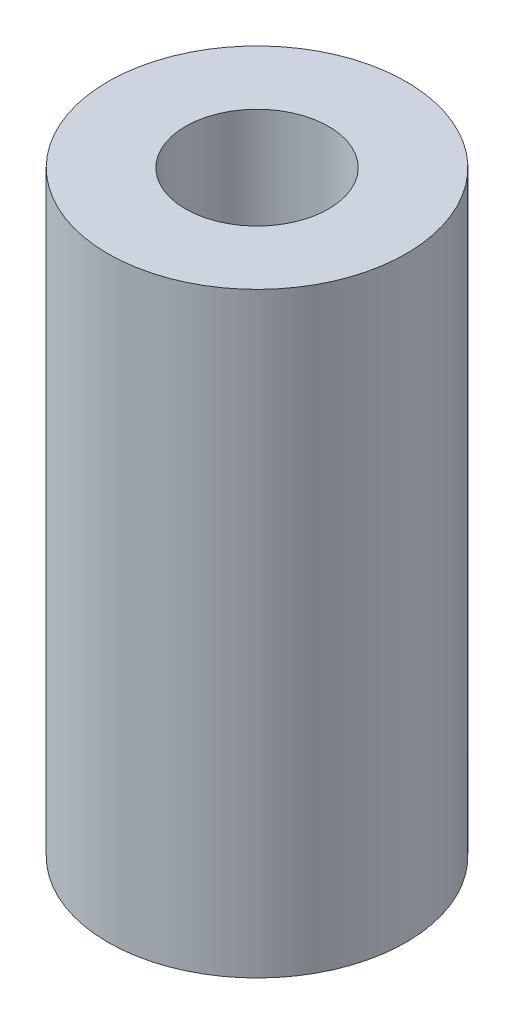
from build123d import *

# Parameters (mm, degrees)
SKIZZE1_R                       = 2.5
AUFSATZ_LINEAR_AUSTRAGEN1_DEPTH = 10
SKIZZE2_R                       = 1.2
SCHNITT_LINEAR_AUSTRAGEN1_DEPTH = 3
SKIZZE3_R                       = 1.2
SCHNITT_LINEAR_AUSTRAGEN2_DEPTH = 3


with BuildPart() as part:
    # Skizze1 → Aufsatz-Linear austragen1 (new body)
    with BuildSketch(Plane(origin=(0, 0, 0), x_dir=(1, 0, 0), z_dir=(0, 1, 0))):
        Circle(SKIZZE1_R)
    extrude(amount=AUFSATZ_LINEAR_AUSTRAGEN1_DEPTH)

    # Skizze2 → Schnitt-Linear austragen1 (cut)
    with BuildSketch(Plane(origin=(0, 10, 0), x_dir=(1, 0, 0), z_dir=(0, 1, 0))):
        Circle(SKIZZE2_R)
    extrude(amount=-SCHNITT_LINEAR_AUSTRAGEN1_DEPTH, mode=Mode.SUBTRACT)

    # Skizze3 → Schnitt-Linear austragen2 (cut)
    with BuildSketch(Plane.XZ):
        Circle(SKIZZE3_R)
    extrude(amount=-SCHNITT_LINEAR_AUSTRAGEN2_DEPTH, mode=Mode.SUBTRACT)


solid = part.part
